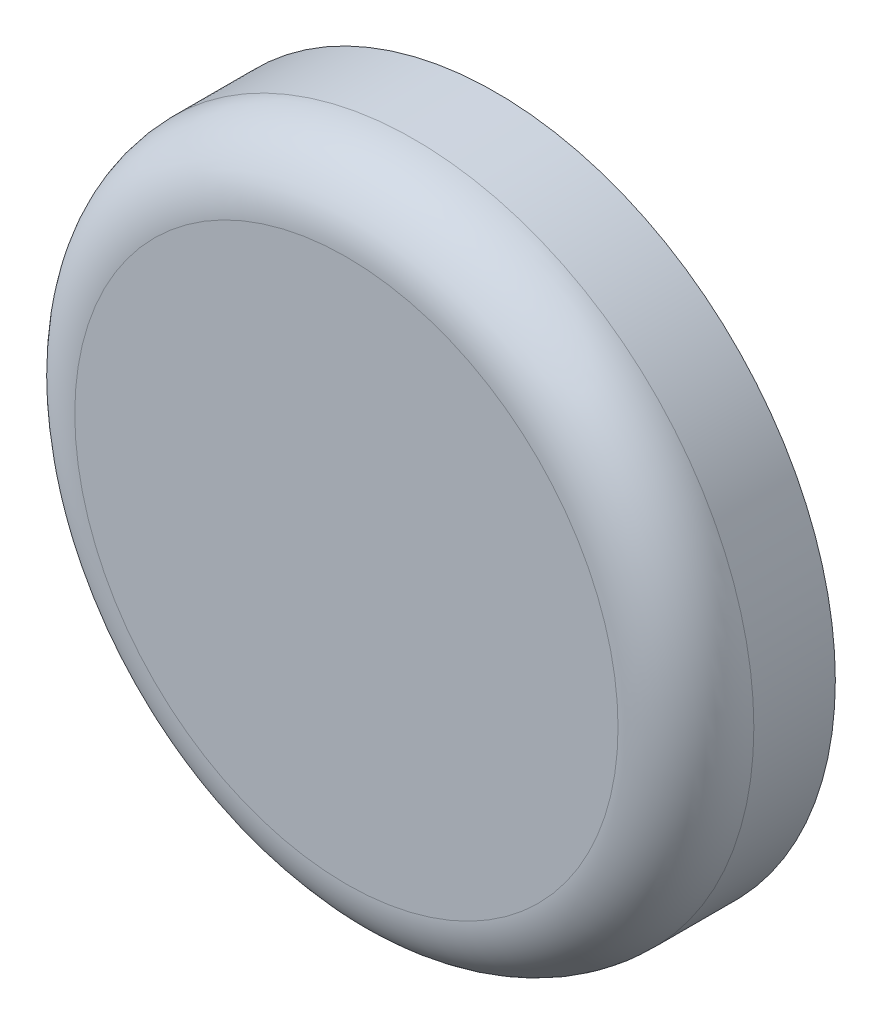
from build123d import *

# Parameters (mm, degrees)
CROQUIS1_R              = 25
SALIENTE_EXTRUIR1_DEPTH = 11
REDONDEO1_R             = 5
CROQUIS2_R              = 5.875
CORTAR_EXTRUIR1_DEPTH   = 9
CROQUIS3_R              = 7
CORTAR_EXTRUIR2_DEPTH   = 4.5


with BuildPart() as part:
    # Croquis1 → Saliente-Extruir1 (new body)
    with BuildSketch(Plane.XY):
        with Locations((-5.625, 13.75)):
            Circle(CROQUIS1_R)
    extrude(amount=SALIENTE_EXTRUIR1_DEPTH)

    # Redondeo1
    redondeo1_edges = [part.edges().sort_by_distance(p)[0] for p in [
        (-30.625, 13.75, 11),
    ]]
    fillet(redondeo1_edges, radius=REDONDEO1_R)

    # Croquis2 → Cortar-Extruir1 (cut)
    with BuildSketch(Plane(origin=(0, 0, 0), x_dir=(-1, 0, 0), z_dir=(0, 0, -1))):
        with Locations((5.625, 13.75)):
            Circle(CROQUIS2_R)
    extrude(amount=-CORTAR_EXTRUIR1_DEPTH, mode=Mode.SUBTRACT)

    # Croquis3 → Cortar-Extruir2 (cut)
    with BuildSketch(Plane(origin=(0, 0, 0), x_dir=(-1, 0, 0), z_dir=(0, 0, -1))):
        with Locations((5.625, 13.75)):
            Circle(CROQUIS3_R)
    extrude(amount=-CORTAR_EXTRUIR2_DEPTH, mode=Mode.SUBTRACT)


solid = part.part
